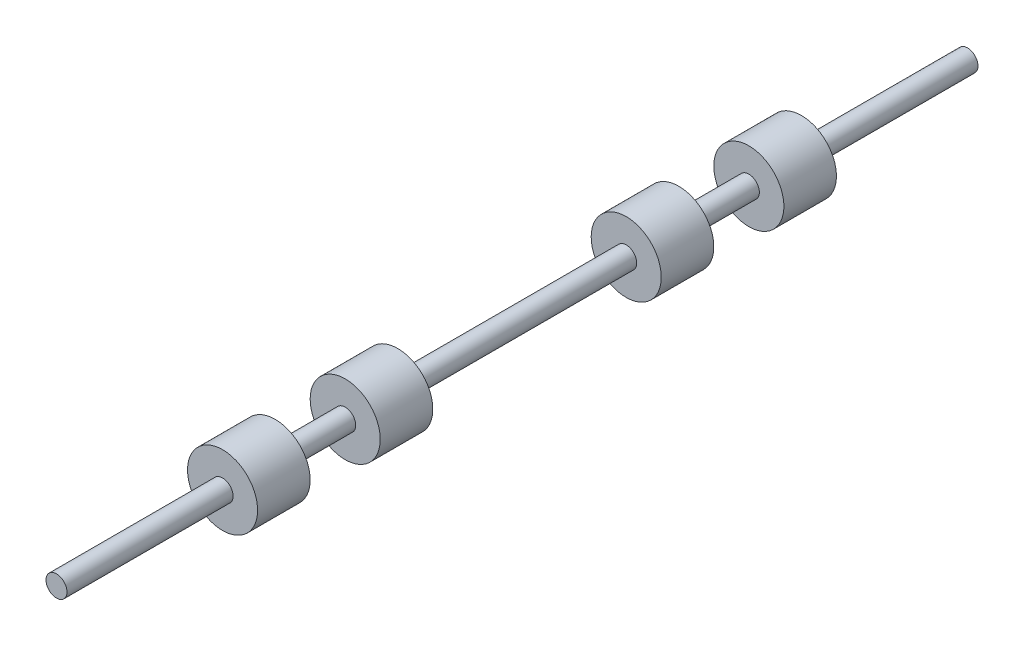
from build123d import *

# Parameters (mm, degrees)
SKETCH1_R           = 0.3
BOSS_EXTRUDE1_DEPTH = 26
SKETCH2_W           = 1
SKETCH2_H           = 1.5


with BuildPart() as part:
    # Sketch1 → Boss-Extrude1 (new body)
    with BuildSketch(Plane.XY):
        Circle(SKETCH1_R)
    extrude(amount=BOSS_EXTRUDE1_DEPTH)


with BuildPart() as body_2:
    # Sketch2 → Revolve1 (revolve)
    with BuildSketch(Plane(origin=(0, 0, 0), x_dir=(1, 0, 0), z_dir=(0, 1, 0))):
        with Locations((0.5, -5.49)):
            Rectangle(SKETCH2_W, SKETCH2_H)
        with Locations((0.5, -8.99)):
            Rectangle(SKETCH2_W, SKETCH2_H)
        with Locations((0.5, -20.51)):
            Rectangle(SKETCH2_W, SKETCH2_H)
        with Locations((0.5, -17.01)):
            Rectangle(SKETCH2_W, SKETCH2_H)
    revolve(axis=Axis((0, 0, 0), (0, 0, 1)))


solid = Compound([part.part, body_2.part])
